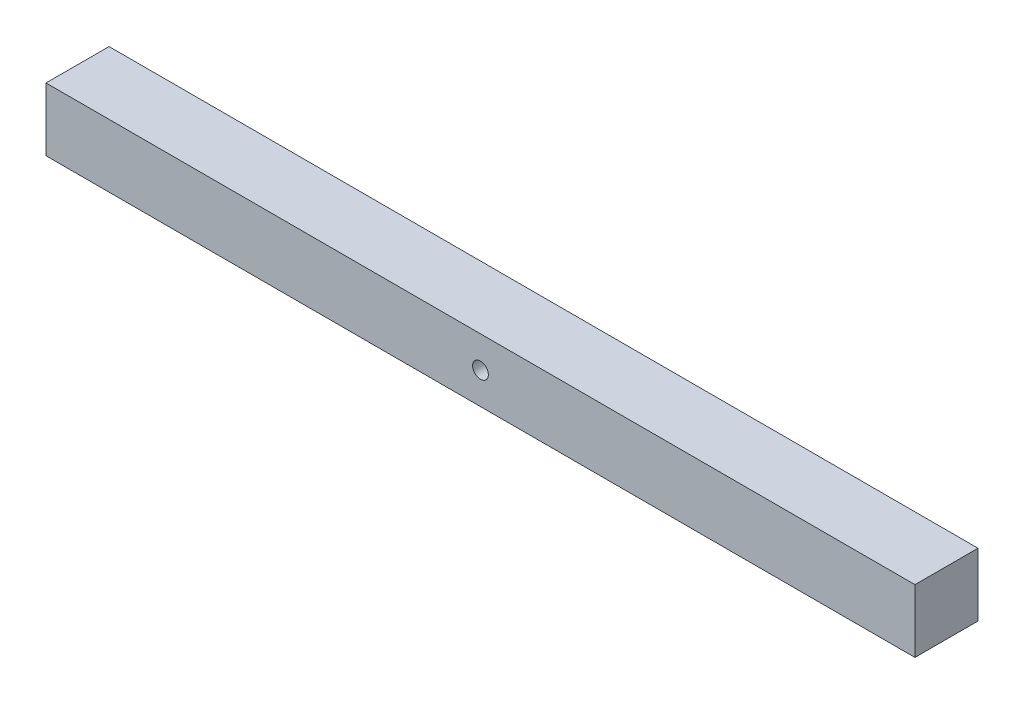
from build123d import *

# Parameters (mm, degrees)
SKETCH1_W           = 700
SKETCH1_H           = 50.8
SKETCH1_R           = 6.35
BOSS_EXTRUDE1_DEPTH = 50.8


with BuildPart() as part:
    # Sketch1 → Boss-Extrude1 (new body)
    with BuildSketch(Plane.XY):
        with Locations((309.712513069, -8.059143226)):
            Rectangle(SKETCH1_W, SKETCH1_H)
        with Locations((309.712513069, -8.059143226)):
            Circle(SKETCH1_R, mode=Mode.SUBTRACT)
    extrude(amount=BOSS_EXTRUDE1_DEPTH)


solid = part.part
